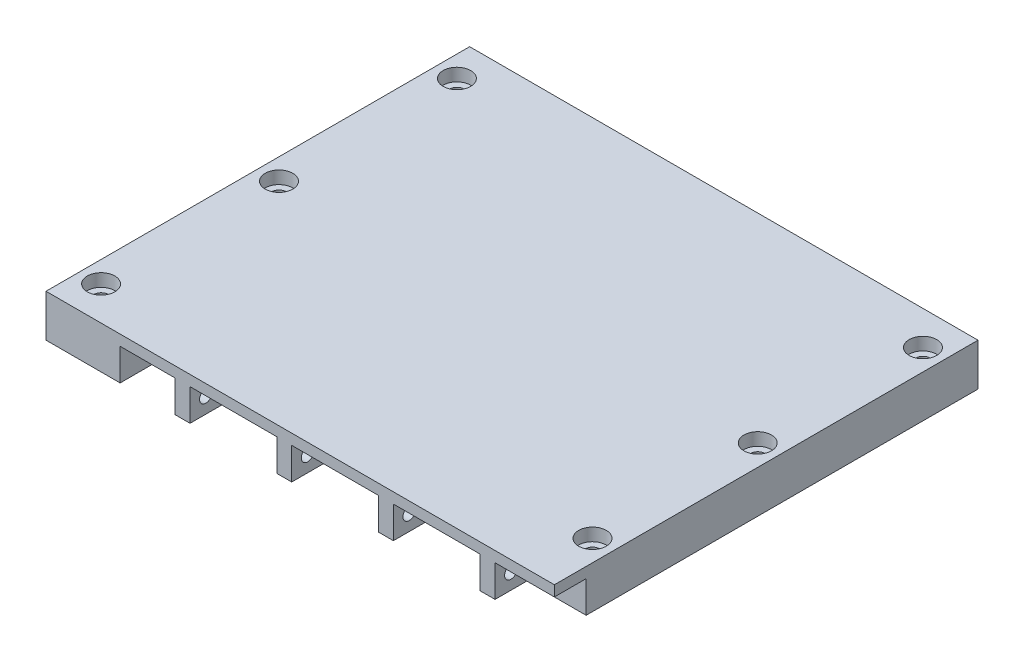
from build123d import *

# Parameters (mm, degrees)
SKETCH1_W                     = 120
SKETCH1_H                     = 100
BOSS_EXTRUDE1_DEPTH           = 10
SKETCH2_W                     = 13
SKETCH2_H                     = 15
CUT_EXTRUDE1_DEPTH            = 35
SKETCH3_W                     = 7.5
SKETCH3_H                     = 7.5
SKETCH3_W_2                   = 14
CUT_EXTRUDE2_DEPTH            = 7.5
SKETCH4_R                     = 1.5
CUT_EXTRUDE3_DEPTH            = 75.5
CBORE_FOR_M3_SHCS_D           = 3.4
CBORE_FOR_M3_SHCS_DEPTH       = 23
CBORE_FOR_M3_SHCS_CBORE_D     = 6.5
CBORE_FOR_M3_SHCS_CBORE_DEPTH = 3
CBORE_FOR_M3_SHCS_TIP         = 1.021463052


with BuildPart() as part:
    # Sketch1 → Boss-Extrude1 (new body)
    with BuildSketch(Plane(origin=(0, 0, 0), x_dir=(1, 0, 0), z_dir=(0, 1, 0))):
        Rectangle(SKETCH1_W, SKETCH1_H)
    extrude(amount=BOSS_EXTRUDE1_DEPTH)

    # Sketch2 → Cut-Extrude1 (cut)
    with BuildSketch(Plane.XY.offset(50)):
        with Locations((-36, 0)):
            Rectangle(SKETCH2_W, SKETCH2_H)
        with Locations((-12, 0)):
            Rectangle(SKETCH2_W, SKETCH2_H)
        with Locations((12, 0)):
            Rectangle(SKETCH2_W, SKETCH2_H)
        with Locations((36, 0)):
            Rectangle(SKETCH2_W, SKETCH2_H)
    extrude(amount=-CUT_EXTRUDE1_DEPTH, mode=Mode.SUBTRACT)

    # Sketch3 → Cut-Extrude2 (cut)
    with BuildSketch(Plane.XY.offset(50)):
        with Locations((-22.25, 3.75)):
            Rectangle(SKETCH3_W, SKETCH3_H)
        with Locations((1.75, 3.75)):
            Rectangle(SKETCH3_W, SKETCH3_H)
        with Locations((25.75, 3.75)):
            Rectangle(SKETCH3_W, SKETCH3_H)
        with Locations((53, 3.75)):
            Rectangle(SKETCH3_W_2, SKETCH3_H)
    extrude(amount=-CUT_EXTRUDE2_DEPTH, mode=Mode.SUBTRACT)

    # Sketch4 → Cut-Extrude3 (cut)
    with BuildSketch(Plane(origin=(46, 0, 0), x_dir=(0, 0, -1), z_dir=(1, 0, 0))):
        with Locations((-46.25, 3.75)):
            Circle(SKETCH4_R)
    extrude(amount=-CUT_EXTRUDE3_DEPTH, mode=Mode.SUBTRACT)

    # CBORE for M3 SHCS
    with Locations(Plane(origin=(-676.293536786, 10, -1323.282701689), x_dir=(1, 0, 0), z_dir=(0, 1, 0))):
        with Locations((731.293536786, -1281.282701689), (731.293536786, -1359.282701689), (621.293536786, -1281.282701689), (621.293536786, -1365.282701689), (621.293536786, -1323.282701689), (731.293536786, -1320.282701689)):
            CounterBoreHole(CBORE_FOR_M3_SHCS_D / 2, CBORE_FOR_M3_SHCS_CBORE_D / 2, CBORE_FOR_M3_SHCS_CBORE_DEPTH, depth=CBORE_FOR_M3_SHCS_DEPTH)
            with Locations((0, 0, -(CBORE_FOR_M3_SHCS_DEPTH + CBORE_FOR_M3_SHCS_TIP / 2))):  # 118° drill point
                Cone(0, CBORE_FOR_M3_SHCS_D / 2, CBORE_FOR_M3_SHCS_TIP, mode=Mode.SUBTRACT)


solid = part.part
